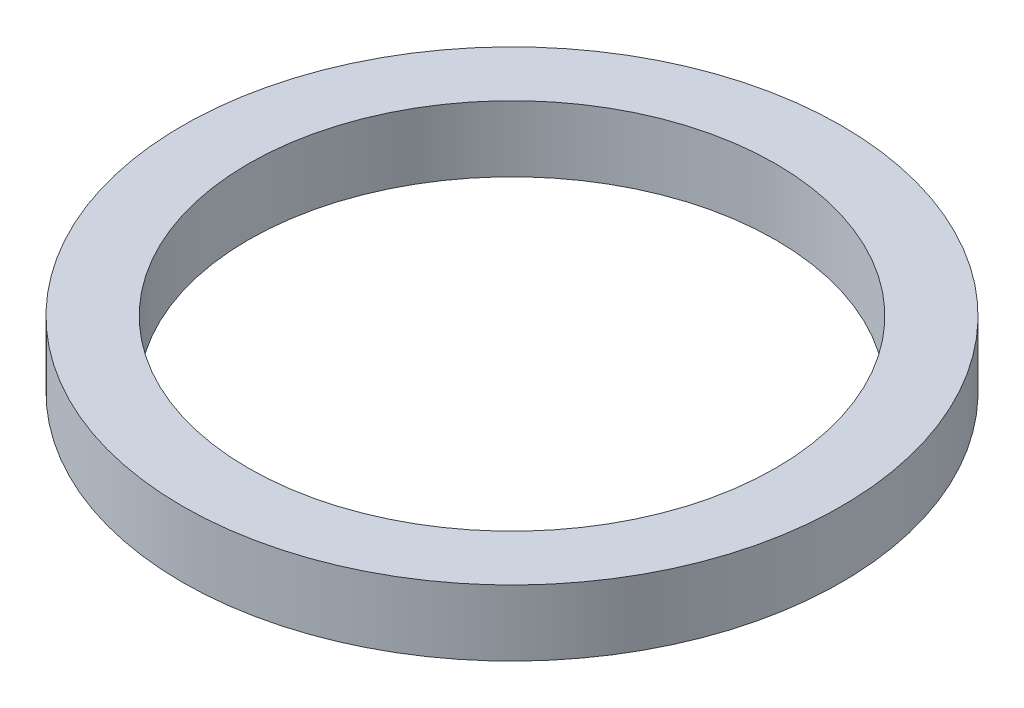
from build123d import *

# Parameters (mm, degrees)
SKETCH_2_R          = 50
EXTRUDE_1_DEPTH     = 10
SKETCH_3_R          = 40
CUT_EXTRUDE_1_DEPTH = 20


with BuildPart() as part:
    # 草图2 → 凸台-拉伸1 (new body)
    with BuildSketch(Plane(origin=(0, 0, 0), x_dir=(1, 0, 0), z_dir=(0, 1, 0))):
        Circle(SKETCH_2_R)
    extrude(amount=EXTRUDE_1_DEPTH)

    # 草图3 → 切除-拉伸1 (cut)
    with BuildSketch(Plane(origin=(0, 10, 0), x_dir=(1, 0, 0), z_dir=(0, 1, 0))):
        Circle(SKETCH_3_R)
    extrude(amount=-CUT_EXTRUDE_1_DEPTH, mode=Mode.SUBTRACT)


solid = part.part
